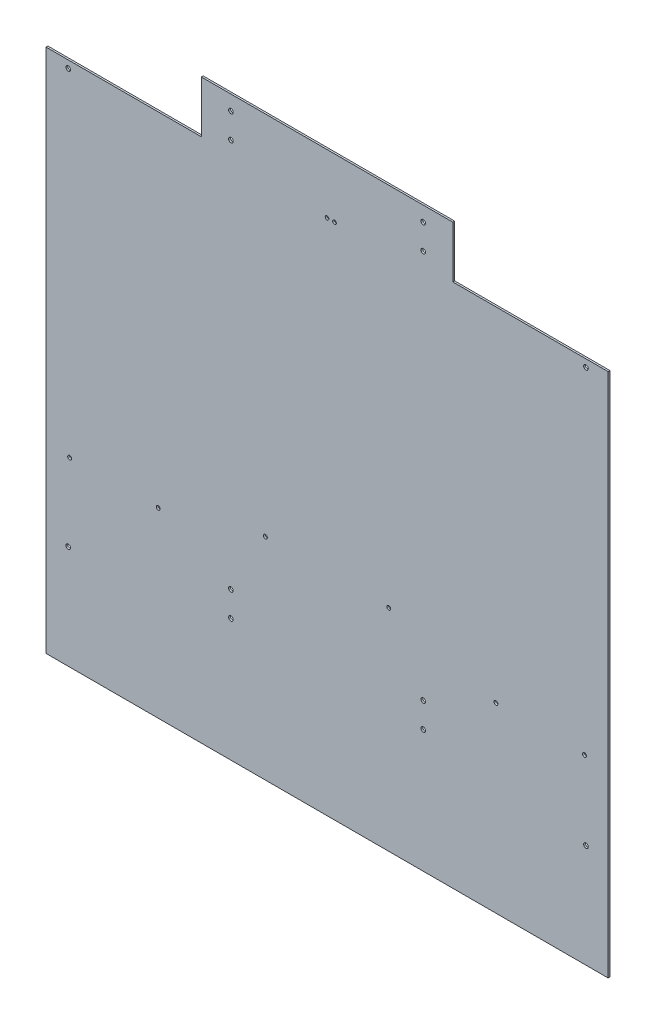
from build123d import *

# Parameters (mm, degrees)
BOSS_EXTRUDE1_DEPTH            = 3.175
F_1_4_CLEARANCE_HOLE1_D        = 6.7564
F_5_16_0_3125_DIAMETER_HOLE1_D = 7.9375
F_1_4_0_25_DIAMETER_HOLE1_D    = 6.35


with BuildPart() as part:
    # Sketch2 → Boss-Extrude1 (new body)
    with BuildSketch(Plane.XY):
        Polygon((-482.6, 901.7), (-215.9, 901.7), (-215.9, 990.6), (215.9, 990.6), (215.9, 901.7), (482.6, 901.7), (482.6, 0), (-482.6, 0), align=None)
    extrude(amount=BOSS_EXTRUDE1_DEPTH)

    # 1/4 Clearance Hole1 (through all)
    with Locations(Plane.XY.offset(3.175)):
        with Locations((-441.96, 311.50918615), (105.907561142, 362.110143283), (289.91643105, 312.805115191), (-289.91643105, 312.805115191), (-105.907561142, 362.110143283), (441.96, 311.50918615)):
            Hole(F_1_4_CLEARANCE_HOLE1_D / 2)

    # 5/16 (0.3125) Diameter Hole1 (through all)
    with Locations(Plane.XY.offset(3.175)):
        with Locations((-165.1, 922.02), (-165.1, 965.2), (165.1, 965.2), (165.1, 922.02), (-165.1, 210.82), (-165.1, 254), (165.1, 254), (165.1, 210.82), (-444.5, 177.8), (444.5, 177.8), (-444.5, 889), (444.5, 889)):
            Hole(F_5_16_0_3125_DIAMETER_HOLE1_D / 2)

    # 1/4 (0.25) Diameter Hole1 (through all)
    with Locations(Plane.XY.offset(3.175)):
        with Locations((0, 889), (12.7, 889)):
            Hole(F_1_4_0_25_DIAMETER_HOLE1_D / 2)


solid = part.part
